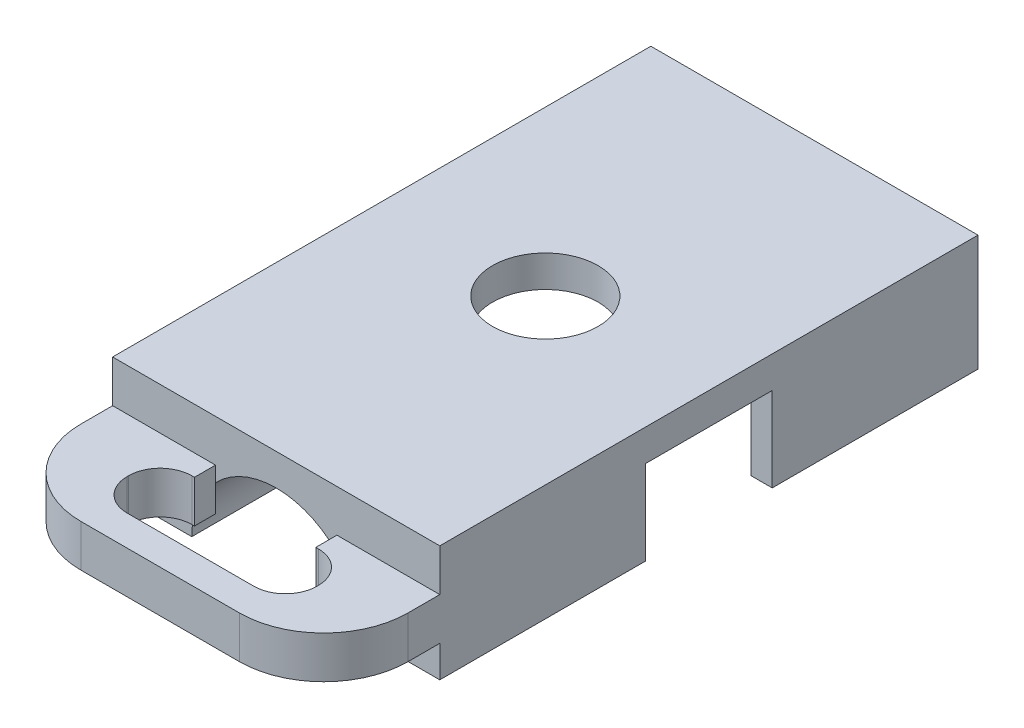
from build123d import *

# Parameters (mm, degrees)
SKETCH_1_W               = 31
SKETCH_1_H               = 51
EXTRUDE_1_DEPTH          = 0.0001
EXTRUDE_1_DEPTH_BACK     = 11
SKETCH_2_W               = 27
SKETCH_2_H               = 12
SKETCH_2_R               = 5
SKETCH_2_W_2             = 2
CUT_EXTRUDE_1_DEPTH      = 0.0001
CUT_EXTRUDE_1_DEPTH_BACK = 8
SKETCH_3_R               = 5
CUT_EXTRUDE_3_DEPTH      = 12
SKETCH_4_R               = 8
CUT_EXTRUDE_4_DEPTH      = 102
EXTRUDE_2_DEPTH          = 4


with BuildPart() as part:
    # Эскиз1 → Бобышка-Вытянуть1 (new, two sides)
    with BuildSketch(Plane(origin=(0, 0, 0), x_dir=(1, 0, 0), z_dir=(0, 1, 0))) as extrude_1_sk:
        Rectangle(SKETCH_1_W, SKETCH_1_H)
    extrude(amount=EXTRUDE_1_DEPTH)
    extrude(extrude_1_sk.sketch, amount=-EXTRUDE_1_DEPTH_BACK)

    # Эскиз2 → Вырез-Вытянуть1 (cut, two sides)
    with BuildSketch(Plane.XZ.offset(11)) as cut_extrude_1_sk:
        with BuildLine():
            Line((-13.5, 11.9058809), (-13.5, 6))
            Line((-13.5, 6), (13.5, 6))
            Line((13.5, 6), (13.5, 11.9058809))
            ThreePointArc((13.5, 11.9058809), (12.152101624, 13.27879611), (10.665364504, 14.5))
            Line((10.665364504, 14.5), (-10.665364504, 14.5))
            ThreePointArc((-10.665364504, 14.5), (-12.152101624, 13.27879611), (-13.5, 11.9058809))
        make_face()
        Rectangle(SKETCH_2_W, SKETCH_2_H)
        with Locations(Location((0, 0, 0), (0, 0, 90))):
            Circle(SKETCH_2_R, mode=Mode.SUBTRACT)
        with Locations((-14.5, 0)):
            Rectangle(SKETCH_2_W_2, SKETCH_2_H)
        with Locations((14.5, 0)):
            Rectangle(SKETCH_2_W_2, SKETCH_2_H)
        with BuildLine():
            Line((13.5, -6), (-13.5, -6))
            Line((-13.5, -6), (-13.5, -11.9058809))
            ThreePointArc((-13.5, -11.9058809), (-12.152101624, -13.27879611), (-10.665364504, -14.5))
            Line((-10.665364504, -14.5), (10.665364504, -14.5))
            ThreePointArc((10.665364504, -14.5), (12.152101624, -13.27879611), (13.5, -11.9058809))
            Line((13.5, -11.9058809), (13.5, -6))
        make_face()
        with BuildLine():
            Line((13.5, -14.5), (13.5, -11.9058809))
            ThreePointArc((13.5, -11.9058809), (12.152101624, -13.27879611), (10.665364504, -14.5))
            Line((10.665364504, -14.5), (13.5, -14.5))
        make_face()
        with BuildLine():
            Line((10.665364504, -14.5), (-10.665364504, -14.5))
            ThreePointArc((-10.665364504, -14.5), (0, -18), (10.665364504, -14.5))
        make_face()
        with BuildLine():
            ThreePointArc((-10.665364504, -14.5), (-12.152101624, -13.27879611), (-13.5, -11.9058809))
            Line((-13.5, -11.9058809), (-13.5, -14.5))
            Line((-13.5, -14.5), (-10.665364504, -14.5))
        make_face()
        with BuildLine():
            Line((-13.5, 14.5), (-13.5, 11.9058809))
            ThreePointArc((-13.5, 11.9058809), (-12.152101624, 13.27879611), (-10.665364504, 14.5))
            Line((-10.665364504, 14.5), (-13.5, 14.5))
        make_face()
        with BuildLine():
            ThreePointArc((10.665364504, 14.5), (0, 18), (-10.665364504, 14.5))
            Line((-10.665364504, 14.5), (10.665364504, 14.5))
        make_face()
        with BuildLine():
            ThreePointArc((10.665364504, 14.5), (12.152101624, 13.27879611), (13.5, 11.9058809))
            Line((13.5, 11.9058809), (13.5, 14.5))
            Line((13.5, 14.5), (10.665364504, 14.5))
        make_face()
    extrude(amount=CUT_EXTRUDE_1_DEPTH, mode=Mode.SUBTRACT)
    extrude(cut_extrude_1_sk.sketch, amount=-CUT_EXTRUDE_1_DEPTH_BACK, mode=Mode.SUBTRACT)

    # Эскиз3 → Вырез-Вытянуть3 (cut)
    with BuildSketch(Plane.XZ.offset(11)):
        with Locations(Location((0, 0, 0), (0, 0, 270))):
            Circle(SKETCH_3_R)
    extrude(amount=-CUT_EXTRUDE_3_DEPTH, mode=Mode.SUBTRACT)

    # Эскиз4 → Вырез-Вытянуть4 (cut)
    with BuildSketch(Plane.XY.offset(25.5)):
        with Locations((0, -11)):
            Circle(SKETCH_4_R)
    extrude(amount=-CUT_EXTRUDE_4_DEPTH, mode=Mode.SUBTRACT)

    # Sketch 1 2 → Бобышка-Вытянуть2 (add)
    with BuildSketch(Plane(origin=(-15.5, -3.9999, 25.5), x_dir=(0.9953500135553002, 0, 0.0963241948601902), z_dir=(0, -1, 0))):
        with BuildLine():
            Line((0, 0), (9.704662632, -0.9391609))
            Line((9.704662632, -0.9391609), (9.897311022, 1.051539127))
            Line((9.897311022, 1.051539127), (9.649856542, 1.075486335))
            ThreePointArc((9.649856542, 1.075486335), (7.62303842, 2.154414617), (6.952779086, 4.35050896))
            Line((6.952779086, 4.35050896), (6.964859124, 4.475336021))
            ThreePointArc((6.964859124, 4.475336021), (8.043787406, 6.502154143), (10.239881749, 7.172413477))
            Line((10.239881749, 7.172413477), (22.181315865, 6.01679082))
            ThreePointArc((22.181315865, 6.01679082), (24.208133987, 4.937862538), (24.878393321, 2.741768195))
            Line((24.878393321, 2.741768195), (24.866313283, 2.616941135))
            ThreePointArc((24.866313283, 2.616941135), (23.787385001, 0.590123012), (21.591290658, -0.080136321))
            Line((21.591290658, -0.080136321), (21.343836178, -0.056189114))
            Line((21.343836178, -0.056189114), (21.151187788, -2.046889141))
            Line((21.151187788, -2.046889141), (30.85585042, -2.986050041))
            Line((30.85585042, -2.986050041), (31.144823005, 0))
            ThreePointArc((31.144823005, 0), (29.357464781, 5.856251582), (23.952616455, 8.733393667))
            Line((23.952616455, 8.733393667), (9.022366252, 10.17825659))
            ThreePointArc((9.022366252, 10.17825659), (3.16611467, 8.390898367), (0.288972585, 2.986050041))
            Line((0.288972585, 2.986050041), (0, 0))
        make_face()
    extrude(amount=EXTRUDE_2_DEPTH)


solid = part.part
